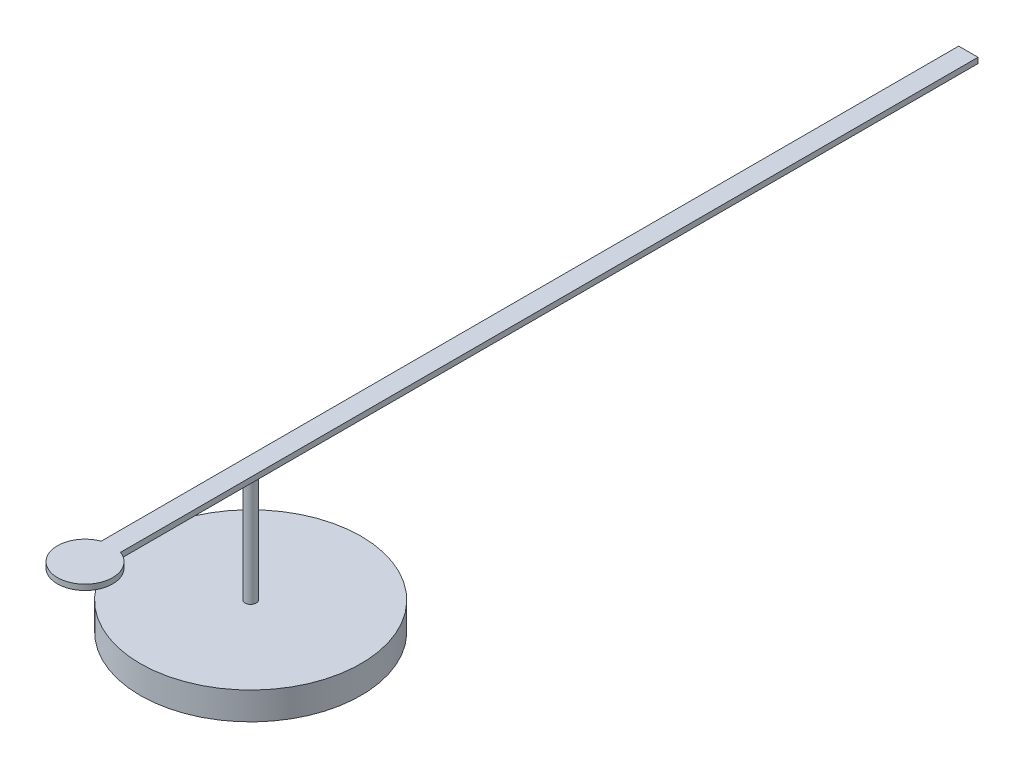
from build123d import *

# Parameters (mm, degrees)
BOSS_EXTRUDE1_DEPTH = 0.1
SKETCH2_R           = 0.1
BOSS_EXTRUDE2_DEPTH = 2
SKETCH3_R           = 2
BOSS_EXTRUDE3_DEPTH = 0.5


with BuildPart() as part:
    # Sketch1 → Boss-Extrude1 (new body)
    with BuildSketch(Plane(origin=(0, 0, 0), x_dir=(1, 0, 0), z_dir=(0, 1, 0))):
        with BuildLine():
            Line((-0.175, 0.46837485), (-0.175, 13))
            Line((-0.175, 13), (0.175, 13))
            Line((0.175, 13), (0.175, 0.46837485))
            Line((0.175, 0.46837485), (0.175, -0.46837485))
            Line((0.175, -0.46837485), (0.175, -2.53162515))
            ThreePointArc((0.175, -2.53162515), (0, -3.5), (-0.175, -2.53162515))
            Line((-0.175, -2.53162515), (-0.175, -0.46837485))
            Line((-0.175, -0.46837485), (-0.175, 0.46837485))
        make_face()
    extrude(amount=BOSS_EXTRUDE1_DEPTH)

    # Sketch2 → Boss-Extrude2 (add)
    with BuildSketch(Plane.XZ):
        Circle(SKETCH2_R)
    extrude(amount=BOSS_EXTRUDE2_DEPTH)

    # Sketch3 → Boss-Extrude3 (add)
    with BuildSketch(Plane.XZ.offset(2)):
        Circle(SKETCH3_R)
    extrude(amount=BOSS_EXTRUDE3_DEPTH)


solid = part.part
